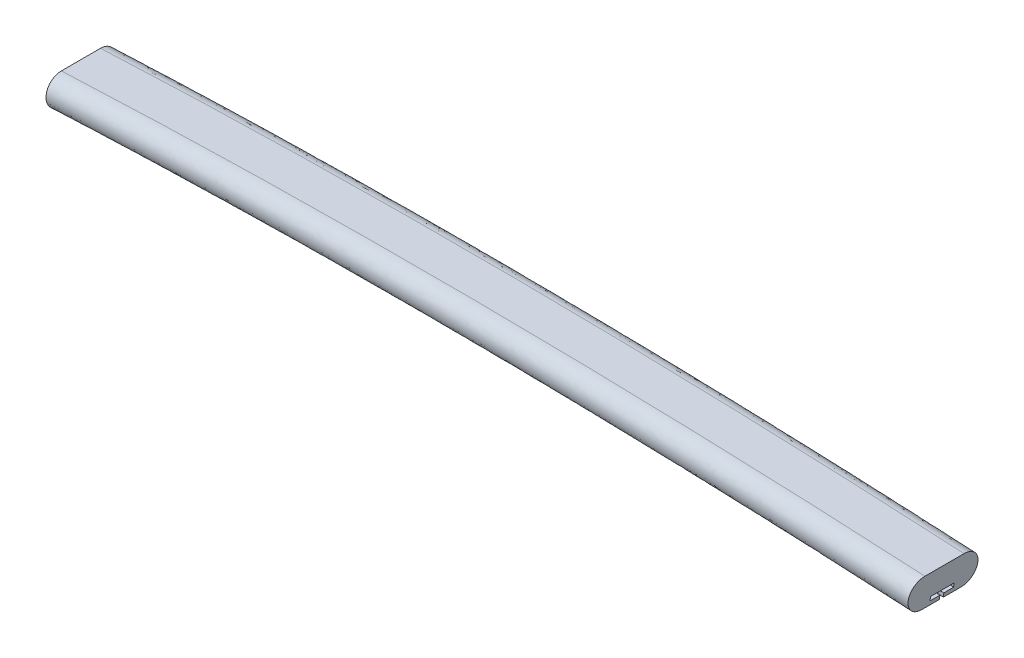
from build123d import *


with BuildPart() as part:
    # Sweep1: sweep along a curve in space
    with BuildLine() as sweep1_path:
        add(Edge.make_bspline(
            [(0, 28.600823045, -25), (515.519545798, 52.9249772, -25), (1099.508665119, 21.327347601, -25)],
            knots=[0, 0, 0, 1, 1, 1], degree=2))
    # Sketch2 → Sweep1 (sweep)
    with BuildSketch(Plane(origin=(0, 0, 0), x_dir=(0, 0, -1), z_dir=(1, 0, 0))):
        with BuildLine():
            Line((0, 48.148148148), (50, 48.148148148))
            ThreePointArc((50, 48.148148148), (69.547325103, 28.600823045), (50, 9.053497942))
            Line((50, 9.053497942), (0, 9.053497942))
            ThreePointArc((0, 9.053497942), (-19.547325103, 28.600823045), (0, 48.148148148))
        make_face()
    sweep(path=sweep1_path.line)

    # Cut-Sweep1: sweep along a curve in space
    with BuildLine() as cut_sweep1_path:
        add(Edge.make_bspline(
            [(0, 28.600823045, -25), (515.519545798, 52.9249772, -25), (1099.508665119, 21.327347601, -25)],
            knots=[0, 0, 0, 1, 1, 1], degree=2))
    # Sketch3 → Cut-Sweep1 (sweep, cut)
    with BuildSketch(Plane.ZY):
        Polygon((-40, 19.053497942), (-10, 19.053497942), (-10, 14.053497942), (-22.5, 14.053497942), (-22.5, 9.053497942), (-22.174756388, 5.22639824), (-27.5, 5.22639824), (-27.5, 9.053497942), (-27.5, 14.053497942), (-40, 14.053497942), align=None)
    sweep(path=cut_sweep1_path.line, mode=Mode.SUBTRACT)


solid = part.part
